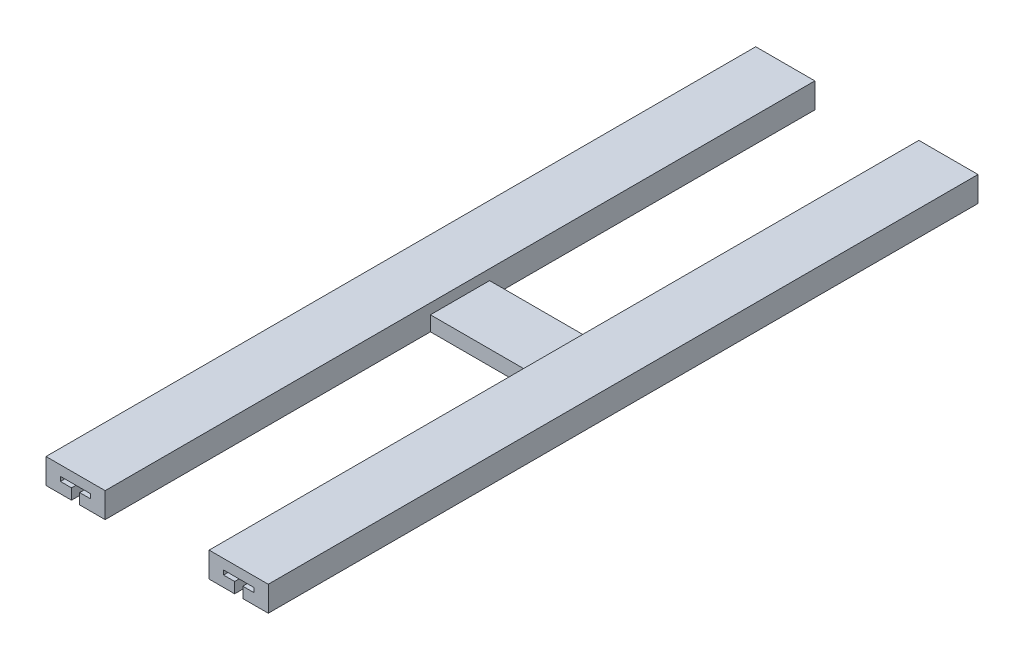
from build123d import *

# Parameters (mm, degrees)
BOSS_EXTRUDE1_DEPTH = 17
SKETCH2_W           = 70
SKETCH2_H           = 40
CUT_EXTRUDE1_DEPTH  = 7
CUT_EXTRUDE2_DEPTH  = 481.331856029


with BuildPart() as part:
    # Sketch1 → Boss-Extrude1 (new body)
    with BuildSketch(Plane(origin=(0, 0, 0), x_dir=(1, 0, 0), z_dir=(0, 1, 0))):
        Polygon((40, 489.668143971), (40, 269.668143971), (110, 269.668143971), (110, 490), (150, 490), (150, 10), (110, 10), (110, 229.668143971), (40, 229.668143971), (40, 9.668143971), (0, 9.668143971), (0, 489.668143971), align=None)
    extrude(amount=BOSS_EXTRUDE1_DEPTH)

    # Sketch2 → Cut-Extrude1 (cut)
    with BuildSketch(Plane(origin=(0, 17, 0), x_dir=(1, 0, 0), z_dir=(0, 1, 0))):
        with Locations((75, 249.668143971)):
            Rectangle(SKETCH2_W, SKETCH2_H)
    extrude(amount=-CUT_EXTRUDE1_DEPTH, mode=Mode.SUBTRACT)

    # Sketch3 → Cut-Extrude2 (cut, through all)
    with BuildSketch(Plane.XY.offset(-9.668143971)):
        Polygon((17.25, 0), (17.25, 7.25), (9.75, 7.25), (9.75, 10.25), (30.25, 10.25), (30.25, 7.25), (22.75, 7.25), (22.75, 0), align=None)
    cut_extrude2 = extrude(amount=-CUT_EXTRUDE2_DEPTH, mode=Mode.SUBTRACT)

    # Mirror1: Cut-Extrude2 across plane
    add(cut_extrude2.mirror(Plane(origin=(75, 0, 0), x_dir=(0, 0, 1), z_dir=(1, 0, 0))), mode=Mode.SUBTRACT)


solid = part.part
